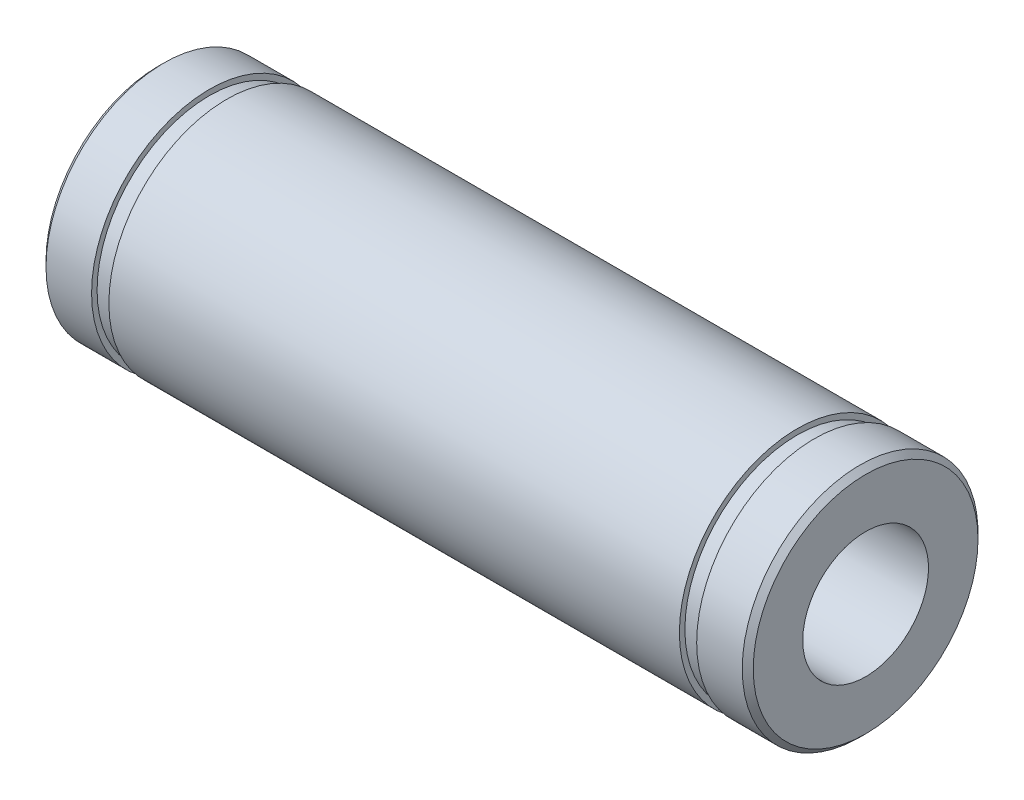
from build123d import *


with BuildPart() as part:
    # Эскиз1 → Повернуть1 (revolve)
    with BuildSketch(Plane(origin=(0, 0, 0), x_dir=(1, 0, 0), z_dir=(0, 1, 0))):
        Polygon((-11.65, -7.5), (-8.75, -7.5), (-8.75, -7.15), (-7.65, -7.15), (-7.65, -7.5), (28.65, -7.5), (28.65, -7.15), (29.75, -7.15), (29.75, -7.5), (32.65, -7.5), (33, -7.15), (33, -4), (-12, -4), (-12, -7.15), align=None)
    revolve(axis=Axis((-14.548038267, 0, 0), (1, 0, 0)))


solid = part.part
